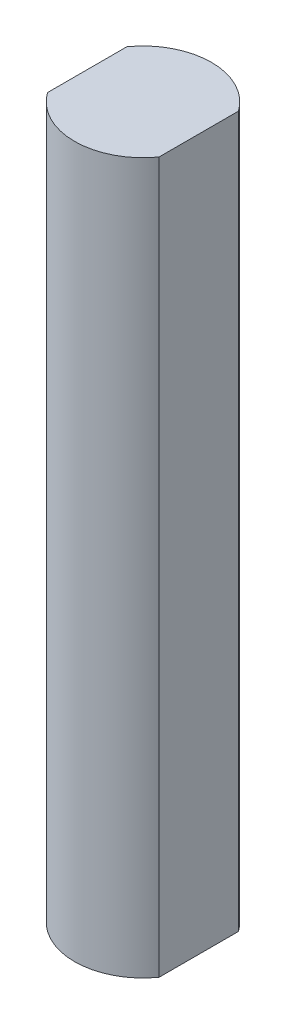
from build123d import *

# Parameters (mm, degrees)
SKETCH1_R           = 4.3815
BOSS_EXTRUDE1_DEPTH = 45.466
CUT_EXTRUDE1_DEPTH  = 48.26


with BuildPart() as part:
    # Sketch1 → Boss-Extrude1 (new body)
    with BuildSketch(Plane(origin=(0, 0, 0), x_dir=(1, 0, 0), z_dir=(0, 1, 0))):
        Circle(SKETCH1_R)
    extrude(amount=BOSS_EXTRUDE1_DEPTH)

    # Sketch2 → Cut-Extrude1 (cut)
    with BuildSketch(Plane(origin=(0, 45.466, 0), x_dir=(1, 0, 0), z_dir=(0, 1, 0))):
        with BuildLine():
            Line((-3.57014597, -2.54), (-3.57014597, 2.54))
            ThreePointArc((-3.57014597, 2.54), (-4.3815, 0), (-3.57014597, -2.54))
        make_face()
        with BuildLine():
            ThreePointArc((4.3815, 0), (4.173735546, 1.333219352), (3.57014597, 2.54))
            Line((3.57014597, 2.54), (3.57014597, -2.54))
            ThreePointArc((3.57014597, -2.54), (4.173735546, -1.333219352), (4.3815, 0))
        make_face()
    extrude(amount=-CUT_EXTRUDE1_DEPTH, mode=Mode.SUBTRACT)


solid = part.part
